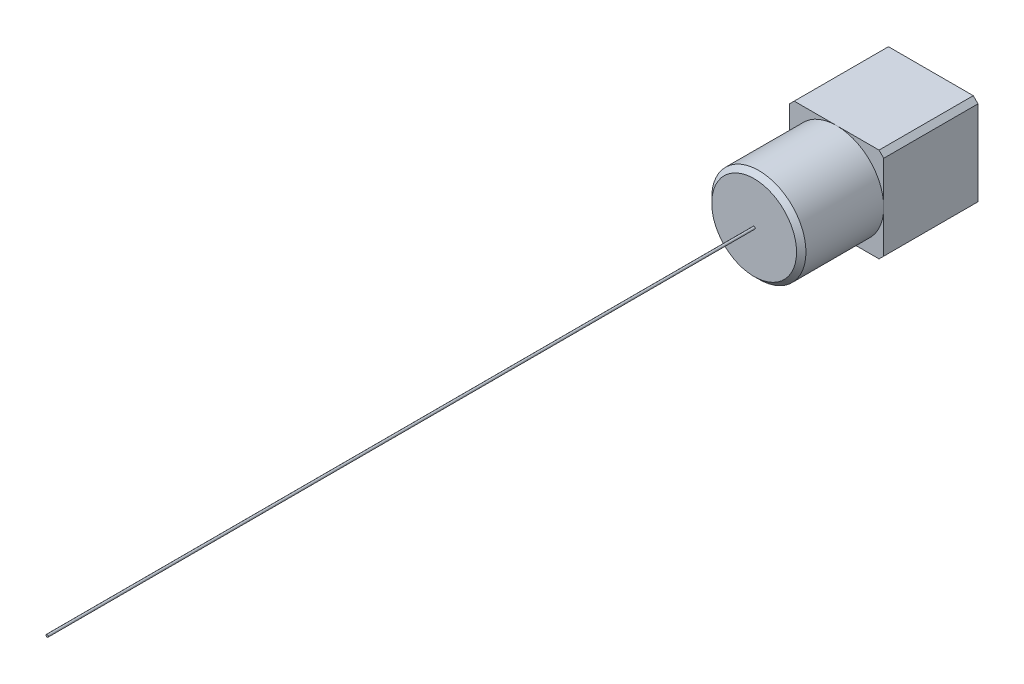
from build123d import *

# Parameters (mm, degrees)
SKETCH_1_W      = 40
SKETCH_1_H      = 40
EXTRUDE_1_DEPTH = 40
SKETCH_2_R      = 20
EXTRUDE_2_DEPTH = 35
SKETCH_8_R      = 3.439176188
EXTRUDE_3_DEPTH = 5
FILLET_3_R      = 0.5
CHAMFER_1_SIZE  = 0.5
CHAMFER_2_SIZE  = 2
CHAMFER_3_SIZE  = 2
SKETCH_9_R      = 0.5
EXTRUDE_4_DEPTH = 300


with BuildPart() as part:
    # 草图1 → 凸台-拉伸1 (new body)
    with BuildSketch(Plane.XY):
        Rectangle(SKETCH_1_W, SKETCH_1_H)
    extrude(amount=EXTRUDE_1_DEPTH)

    # 草图2 → 凸台-拉伸2 (add)
    with BuildSketch(Plane.XY.offset(40)):
        Circle(SKETCH_2_R)
    extrude(amount=EXTRUDE_2_DEPTH)

    # 草图8 → 凸台-拉伸3 (add)
    with BuildSketch(Plane(origin=(0, 0, 0), x_dir=(-1, 0, 0), z_dir=(0, 0, -1))):
        with Locations((8.63222484, 8.081848089)):
            Circle(SKETCH_8_R)
    extrude(amount=EXTRUDE_3_DEPTH)

    # 圆角3
    fillet_3_edges = [part.edges().sort_by_distance(p)[0] for p in [
        (-5.193048652, 8.081848089, 0),
    ]]
    fillet(fillet_3_edges, radius=FILLET_3_R)

    # 倒角1
    chamfer_1_edges = [part.edges().sort_by_distance(p)[0] for p in [
        (-5.193048652, 8.081848089, -5),
    ]]
    chamfer(chamfer_1_edges, length=CHAMFER_1_SIZE)

    # 倒角2
    chamfer_2_edges = [part.edges().sort_by_distance(p)[0] for p in [
        (20, -20, 20),
        (-20, -20, 20),
        (20, 20, 20),
        (-20, 20, 20),
    ]]
    chamfer(chamfer_2_edges, length=CHAMFER_2_SIZE)

    # 倒角3
    chamfer_3_edges = [part.edges().sort_by_distance(p)[0] for p in [
        (-20, 0, 75),
    ]]
    chamfer(chamfer_3_edges, length=CHAMFER_3_SIZE)

    # 草图9 → 凸台-拉伸4 (add)
    with BuildSketch(Plane.XY.offset(75)):
        Circle(SKETCH_9_R)
    extrude(amount=EXTRUDE_4_DEPTH)


solid = part.part
